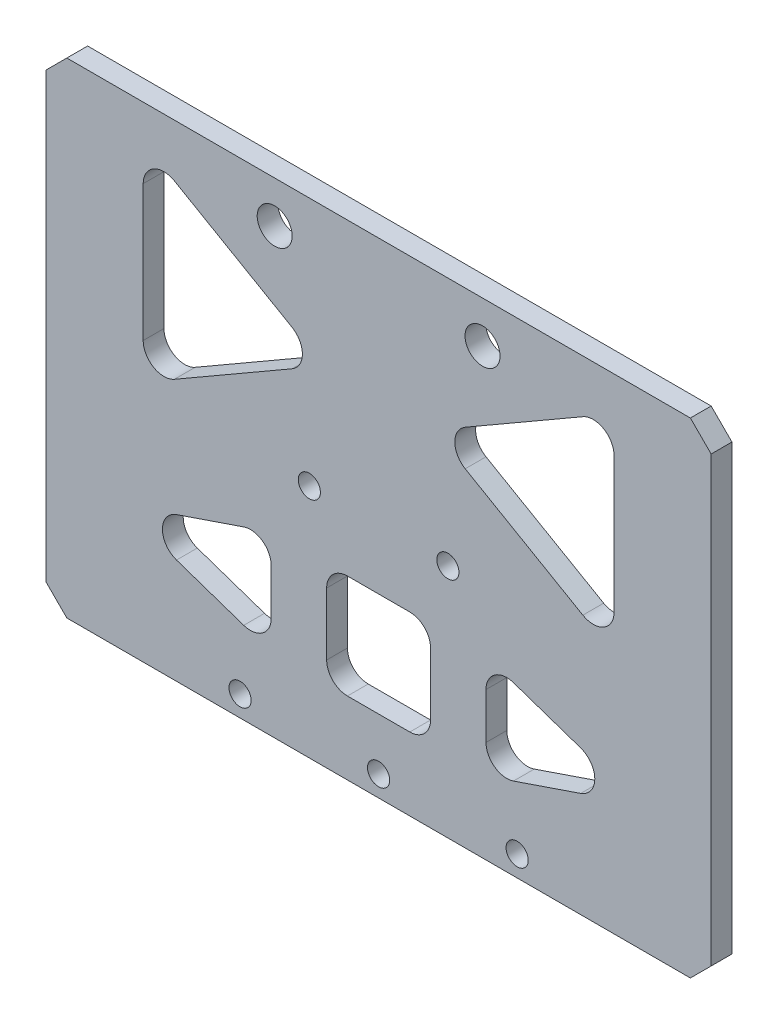
from build123d import *

# Parameters (mm, degrees)
SKETCH_1_W           = 20
SKETCH_1_H           = 40
SKETCH_1_W_2         = 14
SKETCH_1_H_2         = 34
EXTRUDE_1_DEPTH      = 321
SKETCH_15_R          = 2.525
CUT_EXTRUDE_12_DEPTH = 21
SKETCH_18_W          = 17
SKETCH_18_H          = 40
CUT_EXTRUDE_14_DEPTH = 322
SKETCH_19_W          = 96
SKETCH_19_H          = 30
EXTRUDE_2_DEPTH      = 3
SKETCH_17_R          = 1.6
CUT_EXTRUDE_13_DEPTH = 4
FILLET_1_R           = 2
CHAMFER_1_SIZE       = 3
SKETCH_20_W          = 11
SKETCH_20_H          = 22.5
SKETCH_20_W_2        = 15
SKETCH_20_H_2        = 15
CUT_EXTRUDE_15_DEPTH = 4
FILLET_2_R           = 3
CUT_EXTRUDE_16_DEPTH = 4
FILLET_3_R           = 2
SKETCH_22_R          = 1.6
CUT_EXTRUDE_17_DEPTH = 4
CUT_EXTRUDE_19_DEPTH = 10
CHAMFER_2_SIZE       = 3
EXTRUDE_3_DEPTH      = 3
CUT_EXTRUDE_20_DEPTH = 4
FILLET_4_R           = 3


with BuildPart() as part:
    # 草图1 → 凸台-拉伸1 (new body)
    with BuildSketch(Plane(origin=(0, 0, 0), x_dir=(0, 0, -1), z_dir=(1, 0, 0))):
        Rectangle(SKETCH_1_W, SKETCH_1_H)
        Rectangle(SKETCH_1_W_2, SKETCH_1_H_2, mode=Mode.SUBTRACT)
    extrude(amount=EXTRUDE_1_DEPTH)

    # 草图15 → 切除-拉伸12 (cut, through all)
    with BuildSketch(Plane.XY.offset(10)):
        with Locations((145.5, 14)):
            Circle(SKETCH_15_R)
        with Locations((175.5, 14)):
            Circle(SKETCH_15_R)
    extrude(amount=-CUT_EXTRUDE_12_DEPTH, mode=Mode.SUBTRACT)

    # 草图18 → 切除-拉伸14 (cut, through all)
    with BuildSketch(Plane(origin=(321, 0, 0), x_dir=(0, 0, -1), z_dir=(1, 0, 0))):
        with Locations((1.5, 0)):
            Rectangle(SKETCH_18_W, SKETCH_18_H)
    extrude(amount=-CUT_EXTRUDE_14_DEPTH, mode=Mode.SUBTRACT)

    # 草图19 → 凸台-拉伸2 (add)
    with BuildSketch(Plane.XY.offset(10)):
        with Locations((160.5, -35)):
            Rectangle(SKETCH_19_W, SKETCH_19_H)
    extrude(amount=-EXTRUDE_2_DEPTH)

    # 草图17 → 切除-拉伸13 (cut, through all)
    with BuildSketch(Plane.XY.offset(10)):
        with Locations((12, 16.5)):
            Circle(SKETCH_17_R)
        with Locations((29, 16.5)):
            Circle(SKETCH_17_R)
        with Locations((12, -14)):
            Circle(SKETCH_17_R)
        with Locations((29, -14)):
            Circle(SKETCH_17_R)
        with Locations((43.5, -14)):
            Circle(SKETCH_17_R)
        with Locations((67.5, -14)):
            Circle(SKETCH_17_R)
        with Locations((222, -14)):
            Circle(SKETCH_17_R)
        with Locations((239, -14)):
            Circle(SKETCH_17_R)
        with Locations((253.5, -14)):
            Circle(SKETCH_17_R)
        with Locations((277.5, -14)):
            Circle(SKETCH_17_R)
        with Locations((292, -14)):
            Circle(SKETCH_17_R)
        with Locations((309, -14)):
            Circle(SKETCH_17_R)
        with Locations((82, -14)):
            Circle(SKETCH_17_R)
        with Locations((99, -14)):
            Circle(SKETCH_17_R)
        with Locations((292, 16.5)):
            Circle(SKETCH_17_R)
        with Locations((309, 16.5)):
            Circle(SKETCH_17_R)
        with Locations((140.5, -47)):
            Circle(SKETCH_17_R)
        with Locations((160.5, -47)):
            Circle(SKETCH_17_R)
        with Locations((180.5, -47)):
            Circle(SKETCH_17_R)
    extrude(amount=-CUT_EXTRUDE_13_DEPTH, mode=Mode.SUBTRACT)

    # 圆角1
    fillet_1_edges = [part.edges().sort_by_distance(p)[0] for p in [
        (208.5, -20, 8.5),
        (112.5, -20, 8.5),
    ]]
    fillet(fillet_1_edges, radius=FILLET_1_R)

    # 倒角1
    chamfer_1_edges = [part.edges().sort_by_distance(p)[0] for p in [
        (0, 20, 8.5),
        (321, 20, 8.5),
        (0, -20, 8.5),
        (208.5, -50, 8.5),
        (112.5, -50, 8.5),
        (321, -20, 8.5),
    ]]
    chamfer(chamfer_1_edges, length=CHAMFER_1_SIZE)

    # 草图20 → 切除-拉伸15 (cut, through all)
    with BuildSketch(Plane.XY.offset(10)):
        with Locations((300.5, 1.25)):
            Rectangle(SKETCH_20_W, SKETCH_20_H)
        with Locations((20.5, 1.25)):
            Rectangle(SKETCH_20_W, SKETCH_20_H)
        with Locations((160.5, -32)):
            Rectangle(SKETCH_20_W_2, SKETCH_20_H_2)
        Polygon((123, -32), (145, -24.5), (145, -39.5), align=None)
        Polygon((176, -24.5), (176, -39.5), (198, -32), align=None)
    extrude(amount=-CUT_EXTRUDE_15_DEPTH, mode=Mode.SUBTRACT)

    # 圆角2
    fillet_2_edges = [part.edges().sort_by_distance(p)[0] for p in [
        (26, 12.5, 8.5),
        (26, -10, 8.5),
        (15, -10, 8.5),
        (15, 12.5, 8.5),
        (176, -24.5, 8.5),
        (198, -32, 8.5),
        (176, -39.5, 8.5),
        (145, -39.5, 8.5),
        (123, -32, 8.5),
        (145, -24.5, 8.5),
        (168, -24.5, 8.5),
        (168, -39.5, 8.5),
        (153, -39.5, 8.5),
        (153, -24.5, 8.5),
        (306, 12.5, 8.5),
        (306, -10, 8.5),
        (295, -10, 8.5),
        (295, 12.5, 8.5),
    ]]
    fillet(fillet_2_edges, radius=FILLET_2_R)

    # 草图21 → 切除-拉伸16 (cut, through all)
    with BuildSketch(Plane.XY.offset(10)):
        Polygon((33, 6.144919815), (33, -10), (55.199264746, -10), align=None)
        Polygon((181.103828979, -10), (139.896171021, -10), (160.5, 8.609910045), align=None)
        Polygon((67.248892355, -8.871386982), (41.300735254, 10), (88.479202711, 10), align=None)
        Polygon((288, -10), (265.800735254, -10), (288, 6.144919815), align=None)
        Polygon((253.751107645, -8.871386982), (232.520797289, 10), (279.699264746, 10), align=None)
    extrude(amount=-CUT_EXTRUDE_16_DEPTH, mode=Mode.SUBTRACT)

    # 圆角3
    fillet_3_edges = [part.edges().sort_by_distance(p)[0] for p in [
        (279.699264746, 10, 8.5),
        (253.751107645, -8.871386982, 8.5),
        (232.520797289, 10, 8.5),
        (265.800735254, -10, 8.5),
        (288, 6.144919815, 8.5),
        (288, -10, 8.5),
        (160.5, 8.609910045, 8.5),
        (181.103828979, -10, 8.5),
        (139.896171021, -10, 8.5),
        (88.479202711, 10, 8.5),
        (67.248892355, -8.871386982, 8.5),
        (41.300735254, 10, 8.5),
        (33, 6.144919815, 8.5),
        (55.199264746, -10, 8.5),
        (33, -10, 8.5),
    ]]
    fillet(fillet_3_edges, radius=FILLET_3_R)

    # 草图22 → 切除-拉伸17 (cut, through all)
    with BuildSketch(Plane.XY.offset(10)):
        with Locations((150.5, -16)):
            Circle(SKETCH_22_R)
        with Locations((170.5, -16)):
            Circle(SKETCH_22_R)
    extrude(amount=-CUT_EXTRUDE_17_DEPTH, mode=Mode.SUBTRACT)

    # 草图26 → 切除-拉伸19 (cut)
    with BuildSketch(Plane.XY.offset(10)):
        with BuildLine():
            ThreePointArc((110.5, -20), (111.914213562, -20.585786438), (112.5, -22))
            Line((112.5, -22), (112.5, 20))
            Line((112.5, 20), (3, 20))
            Line((3, 20), (0, 17))
            Line((0, 17), (0, -17))
            Line((0, -17), (3, -20))
            Line((3, -20), (110.5, -20))
        make_face()
        with BuildLine():
            ThreePointArc((210.5, -20), (209.085786438, -20.585786438), (208.5, -22))
            Line((208.5, -22), (208.5, 20))
            Line((208.5, 20), (318, 20))
            Line((318, 20), (321, 17))
            Line((321, 17), (321, -17))
            Line((321, -17), (318, -20))
            Line((318, -20), (210.5, -20))
        make_face()
    extrude(amount=-CUT_EXTRUDE_19_DEPTH, mode=Mode.SUBTRACT)

    # 倒角2
    chamfer_2_edges = [part.edges().sort_by_distance(p)[0] for p in [
        (112.5, 20, 8.5),
        (208.5, 20, 8.5),
    ]]
    chamfer(chamfer_2_edges, length=CHAMFER_2_SIZE)

    # 草图27 → 凸台-拉伸3 (add)
    with BuildSketch(Plane.XY.offset(10)):
        with BuildLine():
            Line((145.094256532, -10), (175.905743468, -10))
            ThreePointArc((175.905743468, -10), (177.772346073, -8.718188495), (177.246315984, -6.515794714))
            Line((177.246315984, -6.515794714), (161.840572516, 7.399070354))
            ThreePointArc((161.840572516, 7.399070354), (160.5, 7.914865068), (159.159427484, 7.399070354))
            Line((159.159427484, 7.399070354), (143.753684016, -6.515794714))
            ThreePointArc((143.753684016, -6.515794714), (143.227653927, -8.718188495), (145.094256532, -10))
        make_face()
    extrude(amount=-EXTRUDE_3_DEPTH)

    # 草图28 → 切除-拉伸20 (cut, through all)
    with BuildSketch(Plane.XY.offset(10)):
        Polygon((126.519237886, 15), (152.5, 0), (126.519237886, -15), align=None)
        Polygon((168.5, 0), (194.480762114, -15), (194.480762114, 15), align=None)
    extrude(amount=-CUT_EXTRUDE_20_DEPTH, mode=Mode.SUBTRACT)

    # 圆角4
    fillet_4_edges = [part.edges().sort_by_distance(p)[0] for p in [
        (126.519237886, -15, 8.5),
        (126.519237886, 15, 8.5),
        (152.5, 0, 8.5),
        (168.5, 0, 8.5),
        (194.480762114, 15, 8.5),
        (194.480762114, -15, 8.5),
    ]]
    fillet(fillet_4_edges, radius=FILLET_4_R)


solid = part.part
